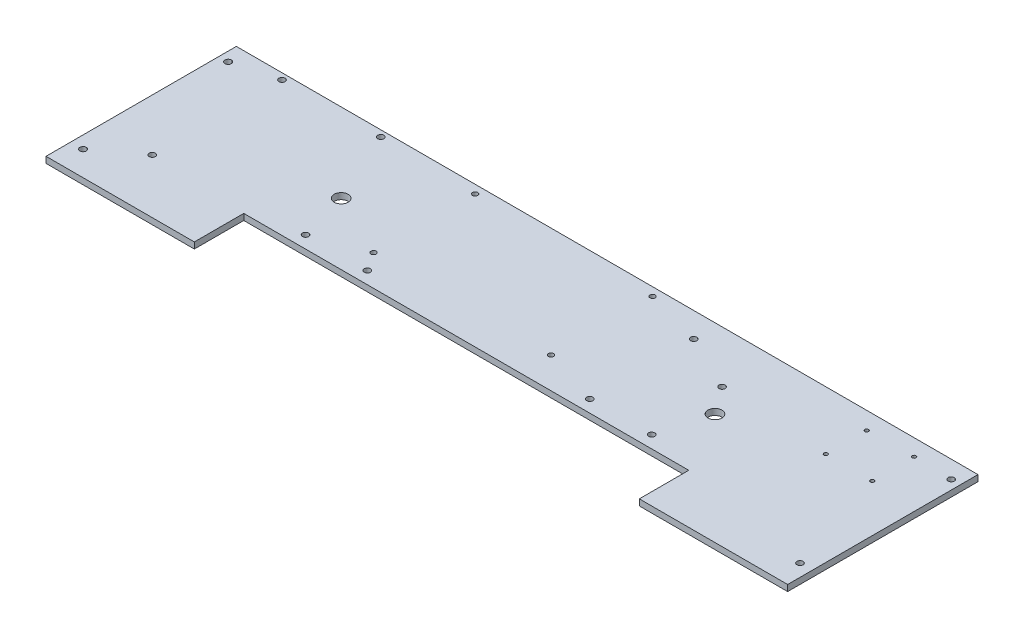
from build123d import *

# Parameters (mm, degrees)
BOSS_EXTRUDE1_DEPTH = 6.35
SKETCH3_R           = 3.302
SKETCH3_R_2         = 3.175
SKETCH3_R_3         = 7.14375
SKETCH3_R_4         = 1.905
CUT_EXTRUDE1_DEPTH  = 7.62
SKETCH5_R           = 2.667
SKETCH5_R_2         = 3.175
CUT_EXTRUDE2_DEPTH  = 7.62


with BuildPart() as part:
    # Sketch1 → Boss-Extrude1 (new body)
    with BuildSketch(Plane(origin=(0, 0, 0), x_dir=(1, 0, 0), z_dir=(0, 1, 0))):
        Polygon((0, 0), (457.2, 0), (457.2, -50.8), (609.6, -50.8), (609.6, 144.78), (-152.4, 144.78), (-152.4, -50.8), (0, -50.8), align=None)
    extrude(amount=BOSS_EXTRUDE1_DEPTH)

    # Sketch3 → Cut-Extrude1 (cut)
    with BuildSketch(Plane(origin=(0, 6.35, 0), x_dir=(1, 0, 0), z_dir=(0, 1, 0))):
        with Locations((-139.7, -25.4)):
            Circle(SKETCH3_R)
        with Locations((-99.1108, 5.0292)):
            Circle(SKETCH3_R_2)
        with Locations((-142.875, 126.81712)):
            Circle(SKETCH3_R)
        with Locations((-99.1108, 138.3792)):
            Circle(SKETCH3_R_2)
        with Locations((2.413, 138.3792)):
            Circle(SKETCH3_R_2)
        with Locations((36.576, 63.5)):
            Circle(SKETCH3_R_3)
        with Locations((600.075, 126.81712)):
            Circle(SKETCH3_R_2)
        with Locations((596.9, -25.4)):
            Circle(SKETCH3_R_2)
        with Locations((560.959, 127.8636)):
            Circle(SKETCH3_R_4)
        with Locations((513.207, 84.8106)):
            Circle(SKETCH3_R_4)
        with Locations((560.959, 84.8106)):
            Circle(SKETCH3_R_4)
        with Locations((513.207, 126.81712)):
            Circle(SKETCH3_R_4)
        with Locations((420.624, 63.5)):
            Circle(SKETCH3_R_3)
    extrude(amount=-CUT_EXTRUDE1_DEPTH, mode=Mode.SUBTRACT)

    # Sketch5 → Cut-Extrude2 (cut)
    with BuildSketch(Plane(origin=(0, 6.35, 0), x_dir=(1, 0, 0), z_dir=(0, 1, 0))):
        with Locations((101.6, 136.144)):
            Circle(SKETCH5_R)
        with Locations((101.6, 31.75)):
            Circle(SKETCH5_R)
        with Locations((400.05, 91.44)):
            Circle(SKETCH5_R_2)
        with Locations((406.4, 12.7)):
            Circle(SKETCH5_R_2)
        with Locations((342.9, 119.38)):
            Circle(SKETCH5_R_2)
        with Locations((342.9, 12.7)):
            Circle(SKETCH5_R_2)
        with Locations((283.8704, 136.144)):
            Circle(SKETCH5_R)
        with Locations((283.8704, 31.75)):
            Circle(SKETCH5_R)
        with Locations((114.3, 12.7)):
            Circle(SKETCH5_R_2)
        with Locations((50.8, 12.7)):
            Circle(SKETCH5_R_2)
    extrude(amount=-CUT_EXTRUDE2_DEPTH, mode=Mode.SUBTRACT)


solid = part.part
